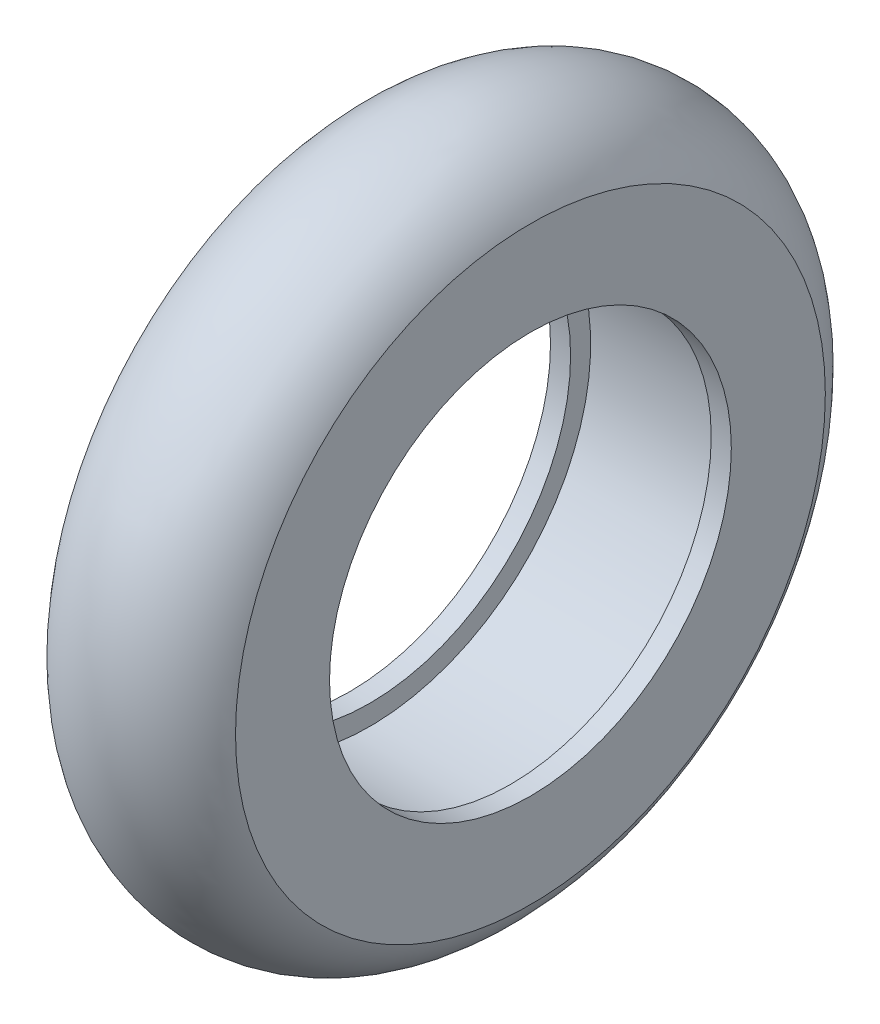
from build123d import *


with BuildPart() as part:
    # Sketch1 → Revolve1 (revolve)
    with BuildSketch(Plane.XY):
        with BuildLine():
            Line((-8, 10), (-9, 10))
            Line((-9, 10), (-9, 14.679449472))
            ThreePointArc((-9, 14.679449472), (-4.5, 17.5), (0, 14.679449472))
            Line((0, 14.679449472), (0, 10))
            Line((0, 10), (-1, 10))
            Line((-1, 10), (-1, 11))
            Line((-1, 11), (-8, 11))
            Line((-8, 11), (-8, 10))
        make_face()
    revolve(axis=Axis((-9, 0, 0), (1, 0, 0)))


solid = part.part
